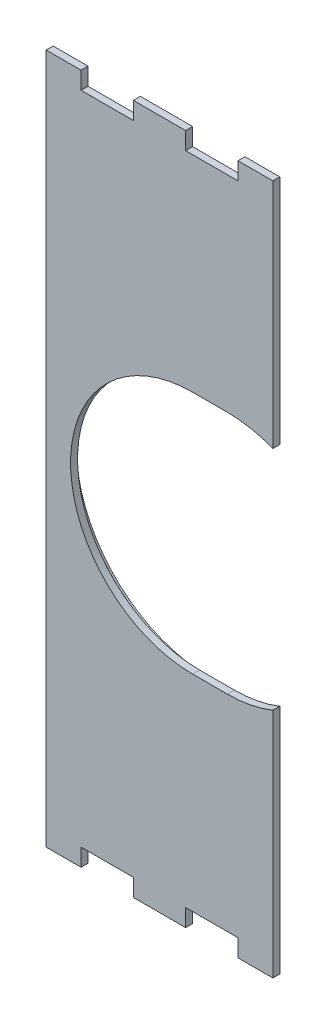
from build123d import *

# Parameters (mm, degrees)
SKETCH1_W           = 82.55
SKETCH1_H           = 251.46
BOSS_EXTRUDE1_DEPTH = 6.35
SKETCH2_W           = 19.05
SKETCH2_H           = 6.35
CUT_EXTRUDE2_DEPTH  = 6.35
SKETCH5_W           = 19.05
SKETCH5_H           = 6.35
CUT_EXTRUDE4_DEPTH  = 6.35
CUT_EXTRUDE5_DEPTH  = 7.35
CUT_EXTRUDE6_DEPTH  = 3.81
CUT_EXTRUDE7_DEPTH  = 2.54
CUT_EXTRUDE8_DEPTH  = 1.27


with BuildPart() as part:
    # Sketch1 → Boss-Extrude1 (new body)
    with BuildSketch(Plane.XY):
        with Locations((-333.375, -120.65)):
            Rectangle(SKETCH1_W, SKETCH1_H)
    extrude(amount=BOSS_EXTRUDE1_DEPTH)

    # Sketch2 → Cut-Extrude2 (cut)
    with BuildSketch(Plane(origin=(0, 5.08, 0), x_dir=(1, 0, 0), z_dir=(0, 1, 0))):
        with Locations((-352.425, -3.175)):
            Rectangle(SKETCH2_W, SKETCH2_H)
        with Locations((-314.325, -3.175)):
            Rectangle(SKETCH2_W, SKETCH2_H)
    extrude(amount=-CUT_EXTRUDE2_DEPTH, mode=Mode.SUBTRACT)

    # Sketch5 → Cut-Extrude4 (cut)
    with BuildSketch(Plane.XZ.offset(246.38)):
        with Locations((-352.425, 3.175)):
            Rectangle(SKETCH5_W, SKETCH5_H)
        with Locations((-314.325, 3.175)):
            Rectangle(SKETCH5_W, SKETCH5_H)
    extrude(amount=-CUT_EXTRUDE4_DEPTH, mode=Mode.SUBTRACT)

    # Sketch6 → Cut-Extrude5 (cut, through all)
    with BuildSketch(Plane.XY.offset(6.35)):
        with BuildLine():
            Line((-321.31, -165.1), (-308.61, -165.1))
            ThreePointArc((-308.61, -165.1), (-264.16, -120.65), (-308.61, -76.2))
            Line((-308.61, -76.2), (-321.31, -76.2))
            ThreePointArc((-321.31, -76.2), (-365.76, -120.65), (-321.31, -165.1))
        make_face()
    extrude(amount=-CUT_EXTRUDE5_DEPTH, mode=Mode.SUBTRACT)

    # Sketch8 → Cut-Extrude6 (cut)
    with BuildSketch(Plane(origin=(0, 0, 0), x_dir=(-1, 0, 0), z_dir=(0, 0, -1))):
        with BuildLine():
            Line((374.65, 5.08), (361.95, 5.08))
            Line((361.95, 5.08), (361.95, -1.27))
            Line((361.95, -1.27), (342.9, -1.27))
            Line((342.9, -1.27), (342.9, 5.08))
            Line((342.9, 5.08), (323.85, 5.08))
            Line((323.85, 5.08), (323.85, -1.27))
            Line((323.85, -1.27), (304.8, -1.27))
            Line((304.8, -1.27), (304.8, 5.08))
            Line((304.8, 5.08), (292.1, 5.08))
            Line((292.1, 5.08), (292.1, -79.379884904))
            ThreePointArc((292.1, -79.379884904), (300.20327995, -77.002210159), (308.61, -76.2))
            Line((308.61, -76.2), (321.31, -76.2))
            ThreePointArc((321.31, -76.2), (365.76, -120.65), (321.31, -165.1))
            Line((321.31, -165.1), (308.61, -165.1))
            ThreePointArc((308.61, -165.1), (300.20327995, -164.297789841), (292.1, -161.920115096))
            Line((292.1, -161.920115096), (292.1, -246.38))
            Line((292.1, -246.38), (304.8, -246.38))
            Line((304.8, -246.38), (304.8, -240.03))
            Line((304.8, -240.03), (323.85, -240.03))
            Line((323.85, -240.03), (323.85, -246.38))
            Line((323.85, -246.38), (342.9, -246.38))
            Line((342.9, -246.38), (342.9, -240.03))
            Line((342.9, -240.03), (361.95, -240.03))
            Line((361.95, -240.03), (361.95, -246.38))
            Line((361.95, -246.38), (374.65, -246.38))
            Line((374.65, -246.38), (374.65, 5.08))
        make_face()
        with BuildLine():
            Line((321.31, -74.422), (308.61, -74.422))
            ThreePointArc((308.61, -74.422), (301.146068779, -75.02853888), (293.878, -76.832239217))
            Line((293.878, -76.832239217), (293.878, 3.302))
            Line((293.878, 3.302), (303.022, 3.302))
            Line((303.022, 3.302), (303.022, -3.048))
            Line((303.022, -3.048), (325.628, -3.048))
            Line((325.628, -3.048), (325.628, 3.302))
            Line((325.628, 3.302), (341.122, 3.302))
            Line((341.122, 3.302), (341.122, -3.048))
            Line((341.122, -3.048), (363.728, -3.048))
            Line((363.728, -3.048), (363.728, 3.302))
            Line((363.728, 3.302), (372.872, 3.302))
            Line((372.872, 3.302), (372.872, -244.602))
            Line((372.872, -244.602), (363.728, -244.602))
            Line((363.728, -244.602), (363.728, -238.252))
            Line((363.728, -238.252), (341.122, -238.252))
            Line((341.122, -238.252), (341.122, -244.602))
            Line((341.122, -244.602), (325.628, -244.602))
            Line((325.628, -244.602), (325.628, -238.252))
            Line((325.628, -238.252), (303.022, -238.252))
            Line((303.022, -238.252), (303.022, -244.602))
            Line((303.022, -244.602), (293.878, -244.602))
            Line((293.878, -244.602), (293.878, -164.467760783))
            ThreePointArc((293.878, -164.467760783), (301.146068779, -166.27146112), (308.61, -166.878))
            Line((308.61, -166.878), (321.31, -166.878))
            ThreePointArc((321.31, -166.878), (367.538, -120.65), (321.31, -74.422))
        make_face(mode=Mode.SUBTRACT)
    extrude(amount=-CUT_EXTRUDE6_DEPTH, mode=Mode.SUBTRACT)

    # Sketch9 → Cut-Extrude7 (cut)
    with BuildSketch(Plane(origin=(0, 0, 0), x_dir=(-1, 0, 0), z_dir=(0, 0, -1))):
        with BuildLine():
            Line((308.61, -74.422), (321.31, -74.422))
            ThreePointArc((321.31, -74.422), (367.538, -120.65), (321.31, -166.878))
            Line((321.31, -166.878), (308.61, -166.878))
            ThreePointArc((308.61, -166.878), (301.146068779, -166.27146112), (293.878, -164.467760783))
            Line((293.878, -164.467760783), (293.878, -244.602))
            Line((293.878, -244.602), (303.022, -244.602))
            Line((303.022, -244.602), (303.022, -238.252))
            Line((303.022, -238.252), (325.628, -238.252))
            Line((325.628, -238.252), (325.628, -244.602))
            Line((325.628, -244.602), (341.122, -244.602))
            Line((341.122, -244.602), (341.122, -238.252))
            Line((341.122, -238.252), (363.728, -238.252))
            Line((363.728, -238.252), (363.728, -244.602))
            Line((363.728, -244.602), (372.872, -244.602))
            Line((372.872, -244.602), (372.872, 3.302))
            Line((372.872, 3.302), (363.728, 3.302))
            Line((363.728, 3.302), (363.728, -3.048))
            Line((363.728, -3.048), (341.122, -3.048))
            Line((341.122, -3.048), (341.122, 3.302))
            Line((341.122, 3.302), (325.628, 3.302))
            Line((325.628, 3.302), (325.628, -3.048))
            Line((325.628, -3.048), (303.022, -3.048))
            Line((303.022, -3.048), (303.022, 3.302))
            Line((303.022, 3.302), (293.878, 3.302))
            Line((293.878, 3.302), (293.878, -76.832239217))
            ThreePointArc((293.878, -76.832239217), (301.146068779, -75.02853888), (308.61, -74.422))
        make_face()
        with BuildLine():
            Line((295.656, -242.824), (295.656, -166.875208707))
            ThreePointArc((295.656, -166.875208707), (302.072084934, -168.208718471), (308.61, -168.656))
            Line((308.61, -168.656), (321.31, -168.656))
            ThreePointArc((321.31, -168.656), (369.316, -120.65), (321.31, -72.644))
            Line((321.31, -72.644), (308.61, -72.644))
            ThreePointArc((308.61, -72.644), (302.072084934, -73.091281529), (295.656, -74.424791293))
            Line((295.656, -74.424791293), (295.656, 1.524))
            Line((295.656, 1.524), (301.244, 1.524))
            Line((301.244, 1.524), (301.244, -4.826))
            Line((301.244, -4.826), (327.406, -4.826))
            Line((327.406, -4.826), (327.406, 1.524))
            Line((327.406, 1.524), (339.344, 1.524))
            Line((339.344, 1.524), (339.344, -4.826))
            Line((339.344, -4.826), (365.506, -4.826))
            Line((365.506, -4.826), (365.506, 1.524))
            Line((365.506, 1.524), (371.094, 1.524))
            Line((371.094, 1.524), (371.094, -242.824))
            Line((371.094, -242.824), (365.506, -242.824))
            Line((365.506, -242.824), (365.506, -236.474))
            Line((365.506, -236.474), (339.344, -236.474))
            Line((339.344, -236.474), (339.344, -242.824))
            Line((339.344, -242.824), (327.406, -242.824))
            Line((327.406, -242.824), (327.406, -236.474))
            Line((327.406, -236.474), (301.244, -236.474))
            Line((301.244, -236.474), (301.244, -242.824))
            Line((301.244, -242.824), (295.656, -242.824))
        make_face(mode=Mode.SUBTRACT)
    extrude(amount=-CUT_EXTRUDE7_DEPTH, mode=Mode.SUBTRACT)

    # Sketch10 → Cut-Extrude8 (cut)
    with BuildSketch(Plane(origin=(0, 0, 0), x_dir=(-1, 0, 0), z_dir=(0, 0, -1))):
        with BuildLine():
            Line((295.656, -166.875208707), (295.656, -242.824))
            Line((295.656, -242.824), (301.244, -242.824))
            Line((301.244, -242.824), (301.244, -236.474))
            Line((301.244, -236.474), (327.406, -236.474))
            Line((327.406, -236.474), (327.406, -242.824))
            Line((327.406, -242.824), (339.344, -242.824))
            Line((339.344, -242.824), (339.344, -236.474))
            Line((339.344, -236.474), (365.506, -236.474))
            Line((365.506, -236.474), (365.506, -242.824))
            Line((365.506, -242.824), (371.094, -242.824))
            Line((371.094, -242.824), (371.094, 1.524))
            Line((371.094, 1.524), (365.506, 1.524))
            Line((365.506, 1.524), (365.506, -4.826))
            Line((365.506, -4.826), (339.344, -4.826))
            Line((339.344, -4.826), (339.344, 1.524))
            Line((339.344, 1.524), (327.406, 1.524))
            Line((327.406, 1.524), (327.406, -4.826))
            Line((327.406, -4.826), (301.244, -4.826))
            Line((301.244, -4.826), (301.244, 1.524))
            Line((301.244, 1.524), (295.656, 1.524))
            Line((295.656, 1.524), (295.656, -74.424791293))
            ThreePointArc((295.656, -74.424791293), (302.072084934, -73.091281529), (308.61, -72.644))
            Line((308.61, -72.644), (321.31, -72.644))
            ThreePointArc((321.31, -72.644), (369.316, -120.65), (321.31, -168.656))
            Line((321.31, -168.656), (308.61, -168.656))
            ThreePointArc((308.61, -168.656), (302.072084934, -168.208718471), (295.656, -166.875208707))
        make_face()
        with BuildLine():
            Line((308.61, -169.418), (321.31, -169.418))
            ThreePointArc((321.31, -169.418), (370.078, -120.65), (321.31, -71.882))
            Line((321.31, -71.882), (308.61, -71.882))
            ThreePointArc((308.61, -71.882), (302.465022664, -72.270695772), (296.418, -73.430587043))
            Line((296.418, -73.430587043), (296.418, 0.762))
            Line((296.418, 0.762), (300.482, 0.762))
            Line((300.482, 0.762), (300.482, -5.588))
            Line((300.482, -5.588), (328.168, -5.588))
            Line((328.168, -5.588), (328.168, 0.762))
            Line((328.168, 0.762), (338.582, 0.762))
            Line((338.582, 0.762), (338.582, -5.588))
            Line((338.582, -5.588), (366.268, -5.588))
            Line((366.268, -5.588), (366.268, 0.762))
            Line((366.268, 0.762), (370.332, 0.762))
            Line((370.332, 0.762), (370.332, -242.062))
            Line((370.332, -242.062), (366.268, -242.062))
            Line((366.268, -242.062), (366.268, -235.712))
            Line((366.268, -235.712), (338.582, -235.712))
            Line((338.582, -235.712), (338.582, -242.062))
            Line((338.582, -242.062), (328.168, -242.062))
            Line((328.168, -242.062), (328.168, -235.712))
            Line((328.168, -235.712), (300.482, -235.712))
            Line((300.482, -235.712), (300.482, -242.062))
            Line((300.482, -242.062), (296.418, -242.062))
            Line((296.418, -242.062), (296.418, -167.869412957))
            ThreePointArc((296.418, -167.869412957), (302.465022664, -169.029304228), (308.61, -169.418))
        make_face(mode=Mode.SUBTRACT)
    extrude(amount=-CUT_EXTRUDE8_DEPTH, mode=Mode.SUBTRACT)


solid = part.part
